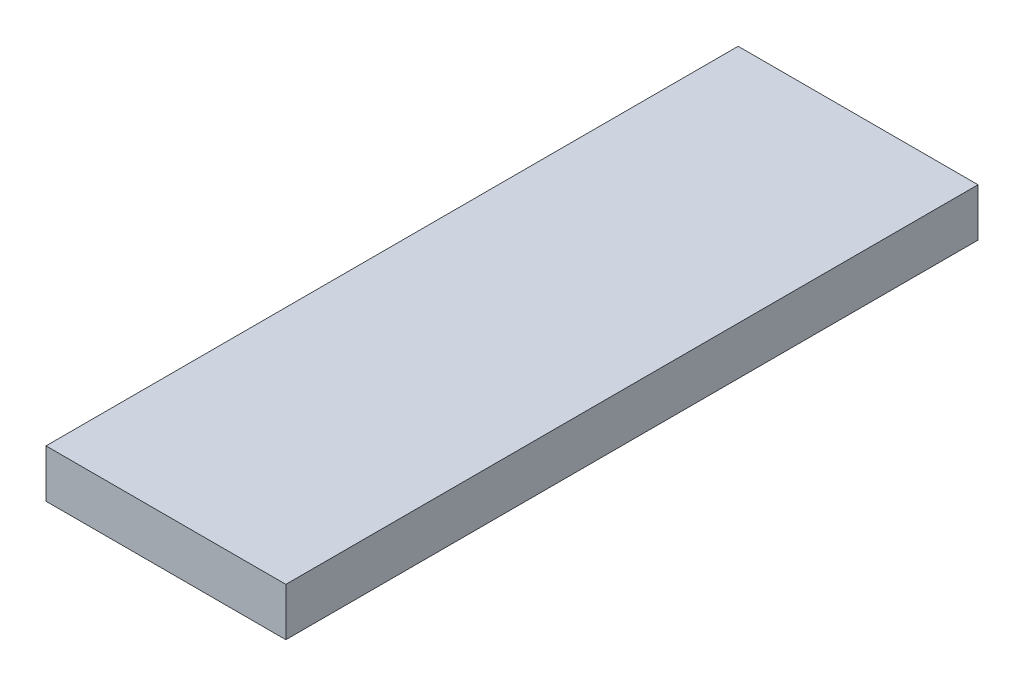
from build123d import *

# Parameters (mm, degrees)
SKETCH1_W           = 35
SKETCH1_H           = 101
BOSS_EXTRUDE1_DEPTH = 7


with BuildPart() as part:
    # Sketch1 → Boss-Extrude1 (new body)
    with BuildSketch(Plane(origin=(0, 0, 0), x_dir=(1, 0, 0), z_dir=(0, 1, 0))):
        Rectangle(SKETCH1_W, SKETCH1_H)
    extrude(amount=BOSS_EXTRUDE1_DEPTH)


solid = part.part
